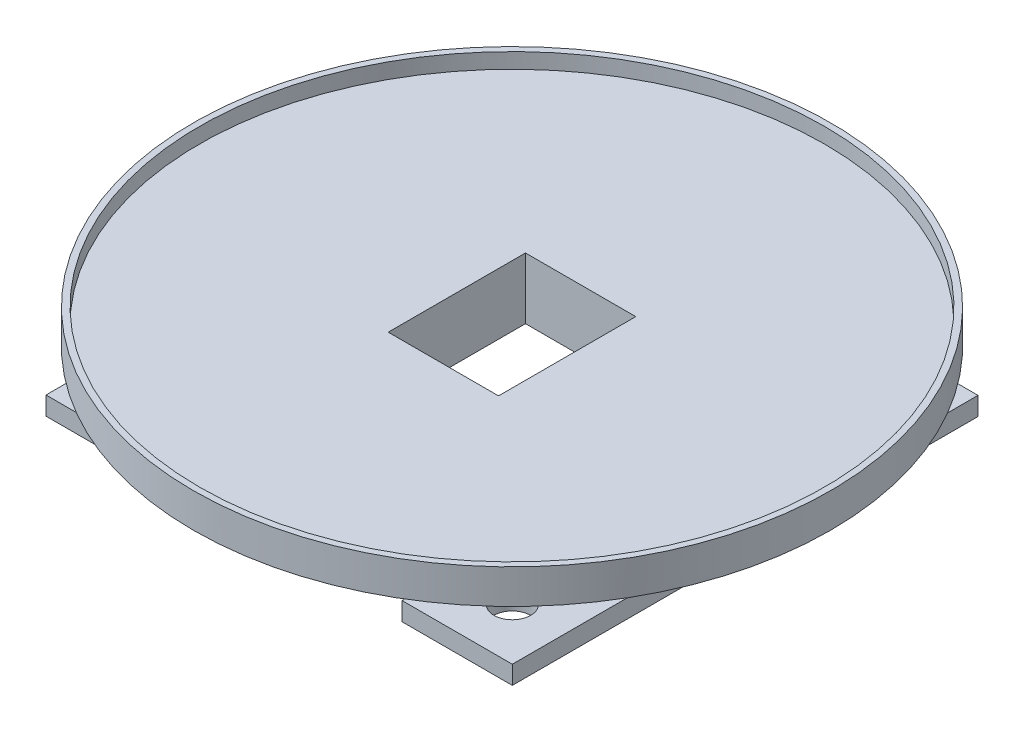
from build123d import *

# Parameters (mm, degrees)
SKETCH7_R             = 25.5
SKETCH7_W             = 9
SKETCH7_H             = 11.2
LENS_SPACER_DEPTH     = 5
SKETCH5_W             = 9
SKETCH5_H             = 38
SKETCH5_R             = 1.5
ATTACHMENT_LEGS_DEPTH = 1.5
LENS_START            = -5
SKETCH8_R             = 26
SKETCH8_R_2           = 25.5
LENS_POSITIONER_DEPTH = 6.25
SKETCH11_W            = 4
SKETCH11_H            = 3
NODE_HOLE_DEPTH       = 0.7


with BuildPart() as part:
    # Sketch7 → Lens Spacer (new body)
    with BuildSketch(Plane.XZ):
        Circle(SKETCH7_R)
        Rectangle(SKETCH7_W, SKETCH7_H, mode=Mode.SUBTRACT)
    extrude(amount=LENS_SPACER_DEPTH)

    # Sketch5 → Attachment Legs (add)
    with BuildSketch(Plane(origin=(0, -5, 0), x_dir=(-1, 0, 0), z_dir=(0, -1, 0))):
        with Locations((-14.525, 0)):
            Rectangle(SKETCH5_W, SKETCH5_H)
        with Locations((-14.825, 14.8)):
            Circle(SKETCH5_R, mode=Mode.SUBTRACT)
        with Locations((-14.825, -14.8)):
            Circle(SKETCH5_R, mode=Mode.SUBTRACT)
        with Locations((14.525, 0)):
            Rectangle(SKETCH5_W, SKETCH5_H)
        with Locations((15.175, -14.8)):
            Circle(SKETCH5_R, mode=Mode.SUBTRACT)
        with Locations((15.175, 14.8)):
            Circle(SKETCH5_R, mode=Mode.SUBTRACT)
    extrude(amount=ATTACHMENT_LEGS_DEPTH)

    # Sketch8 → Lens Positioner (add)
    with BuildSketch(Plane(origin=(0, 0, 0), x_dir=(1, 0, 0), z_dir=(0, 1, 0)).offset(LENS_START)):
        Circle(SKETCH8_R)
        Circle(SKETCH8_R_2, mode=Mode.SUBTRACT)
    extrude(amount=LENS_POSITIONER_DEPTH)

    # Sketch11 → Node Hole (cut)
    with BuildSketch(Plane.XZ.offset(6.5)):
        with Locations((14.868591599, -9.123908481)):
            Rectangle(SKETCH11_W, SKETCH11_H)
    extrude(amount=-NODE_HOLE_DEPTH, mode=Mode.SUBTRACT)

    # Sketch13 → Cut-Revolve1 (revolve, cut)
    with BuildSketch(Plane.XY):
        with BuildLine():
            ThreePointArc((-16, -5), (-20.846735107, -2.830753933), (-26, -1.55))
            Line((-26, -1.55), (-26, -5))
            Line((-26, -5), (-16, -5))
        make_face()
        with BuildLine():
            Line((-23.315412737, -5), (-16, -5))
            ThreePointArc((-16, -5), (-19.657706368, -4.047609039), (-23.315412737, -5))
        make_face()
    revolve(axis=Axis((0, -78.539105243, 0), (0, 1, 0)), mode=Mode.SUBTRACT)


solid = part.part
